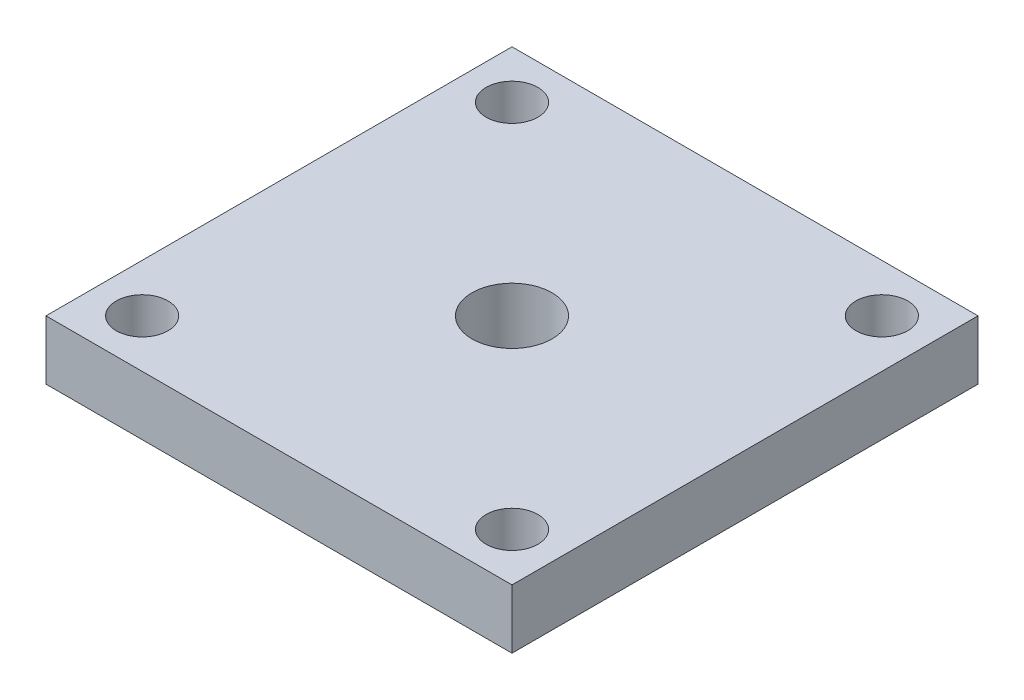
from build123d import *

# Parameters (mm, degrees)
SKETCH1_W                  = 31.5
SKETCH1_H                  = 31.5
BOSS_EXTRUDE1_DEPTH        = 4
F_3_5_3_5_DIAMETER_HOLE1_D = 3.5
F_1_4_28_TAPPED_HOLE1_D    = 5.4102


with BuildPart() as part:
    # Sketch1 → Boss-Extrude1 (new body)
    with BuildSketch(Plane(origin=(0, 0, 0), x_dir=(1, 0, 0), z_dir=(0, 1, 0))):
        Rectangle(SKETCH1_W, SKETCH1_H)
    extrude(amount=BOSS_EXTRUDE1_DEPTH)

    # Ø3.5 (3.5) Diameter Hole1 (through all)
    with Locations(Plane(origin=(0, 4, 0), x_dir=(1, 0, 0), z_dir=(0, 1, 0))):
        with Locations((-12.5, 12.5), (12.5, 12.5), (12.5, -12.5), (-12.5, -12.5)):
            Hole(F_3_5_3_5_DIAMETER_HOLE1_D / 2)

    # 1/4-28 Tapped Hole1 (through all)
    with Locations(Plane(origin=(0, 4, 0), x_dir=(1, 0, 0), z_dir=(0, 1, 0))):
        with Locations((0, 0)):
            Hole(F_1_4_28_TAPPED_HOLE1_D / 2)


solid = part.part
